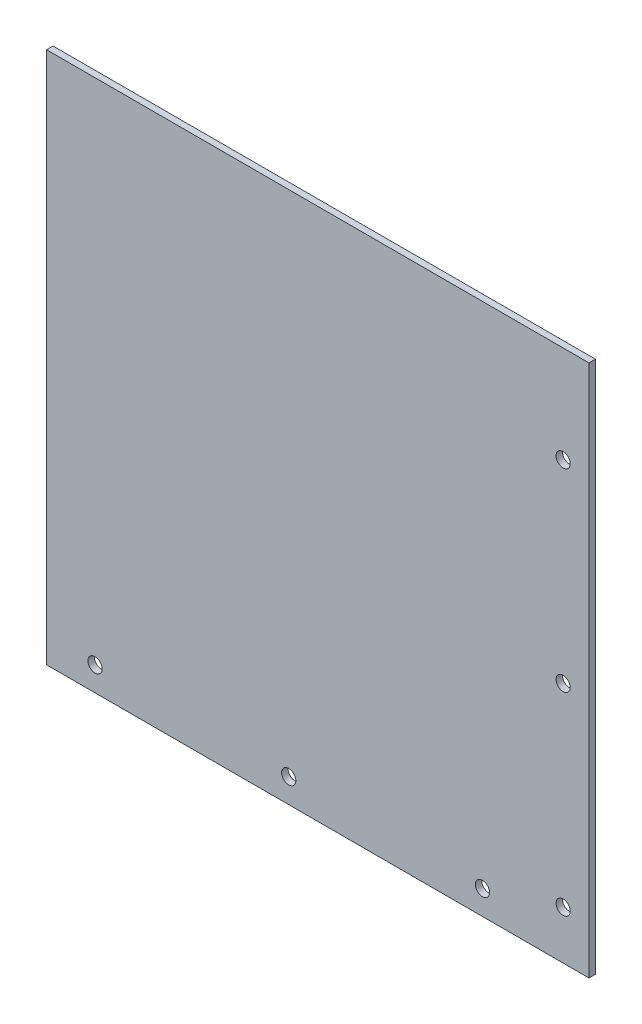
from build123d import *

# Parameters (mm, degrees)
SKETCH_1_W          = 168
SKETCH_1_H          = 167
EXTRUDE_1_DEPTH     = 2
SKETCH_2_R          = 2.2
CUT_EXTRUDE_1_DEPTH = 2
SKETCH_3_W          = 168
SKETCH_3_H          = 2
CUT_EXTRUDE_2_DEPTH = 2
SKETCH_4_R          = 2.2
CUT_EXTRUDE_3_DEPTH = 2


with BuildPart() as part:
    # ｽｹｯﾁ1 → ﾎﾞｽ - 押し出し1 (new body)
    with BuildSketch(Plane.XY):
        Rectangle(SKETCH_1_W, SKETCH_1_H)
    extrude(amount=EXTRUDE_1_DEPTH)

    # ｽｹｯﾁ2 → ｶｯﾄ - 押し出し1 (cut)
    with BuildSketch(Plane.XY.offset(2)):
        with Locations((76, -68.5)):
            Circle(SKETCH_2_R)
        with Locations((76, -8.5)):
            Circle(SKETCH_2_R)
        with Locations((76, 51.5)):
            Circle(SKETCH_2_R)
    extrude(amount=-CUT_EXTRUDE_1_DEPTH, mode=Mode.SUBTRACT)

    # ｽｹｯﾁ3 → ｶｯﾄ - 押し出し2 (cut)
    with BuildSketch(Plane(origin=(0, 83.5, 0), x_dir=(1, 0, 0), z_dir=(0, 1, 0))):
        with Locations((0, -1)):
            Rectangle(SKETCH_3_W, SKETCH_3_H)
    extrude(amount=-CUT_EXTRUDE_2_DEPTH, mode=Mode.SUBTRACT)

    # ｽｹｯﾁ4 → ｶｯﾄ - 押し出し3 (cut)
    with BuildSketch(Plane.XY.offset(2)):
        with BuildLine():
            ThreePointArc((-6.8, -76), (-9, -73.8), (-11.2, -76))
            Line((-11.2, -76), (-9, -76))
            Line((-9, -76), (-6.8, -76))
        make_face()
        with BuildLine():
            Line((-9, -76), (-11.2, -76))
            ThreePointArc((-11.2, -76), (-9, -78.2), (-6.8, -76))
            Line((-6.8, -76), (-9, -76))
        make_face()
        with BuildLine():
            ThreePointArc((-66.8, -76), (-69, -73.8), (-71.2, -76))
            Line((-71.2, -76), (-69, -76))
            Line((-69, -76), (-66.8, -76))
        make_face()
        with BuildLine():
            Line((-69, -76), (-71.2, -76))
            ThreePointArc((-71.2, -76), (-69, -78.2), (-66.8, -76))
            Line((-66.8, -76), (-69, -76))
        make_face()
        with Locations((51, -76)):
            Circle(SKETCH_4_R)
    extrude(amount=-CUT_EXTRUDE_3_DEPTH, mode=Mode.SUBTRACT)


solid = part.part
